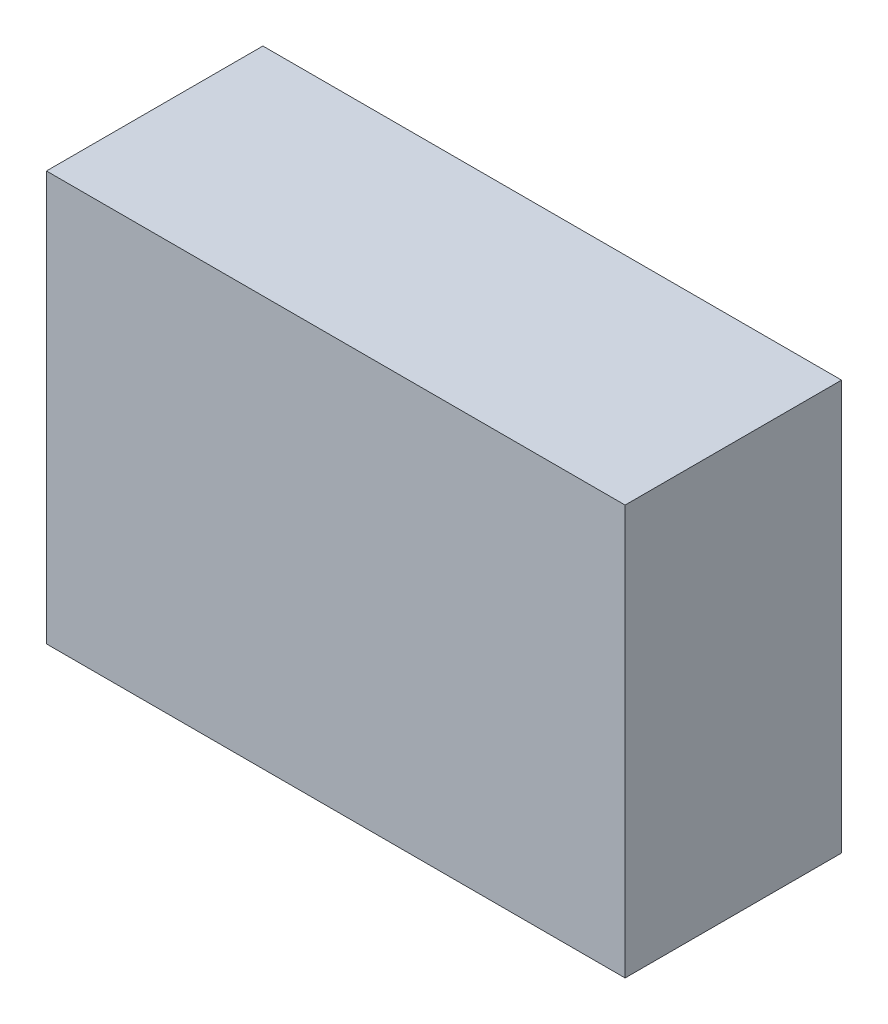
from build123d import *

# Parameters (mm, degrees)
ESBO_O1_W                = 770
ESBO_O1_H                = 545
RESSALTO_EXTRUS_O1_DEPTH = 288


with BuildPart() as part:
    # Esboço1 → Ressalto-extrusão1 (new body)
    with BuildSketch(Plane.XY):
        with Locations((385, 272.5)):
            Rectangle(ESBO_O1_W, ESBO_O1_H)
    extrude(amount=RESSALTO_EXTRUS_O1_DEPTH)


solid = part.part
